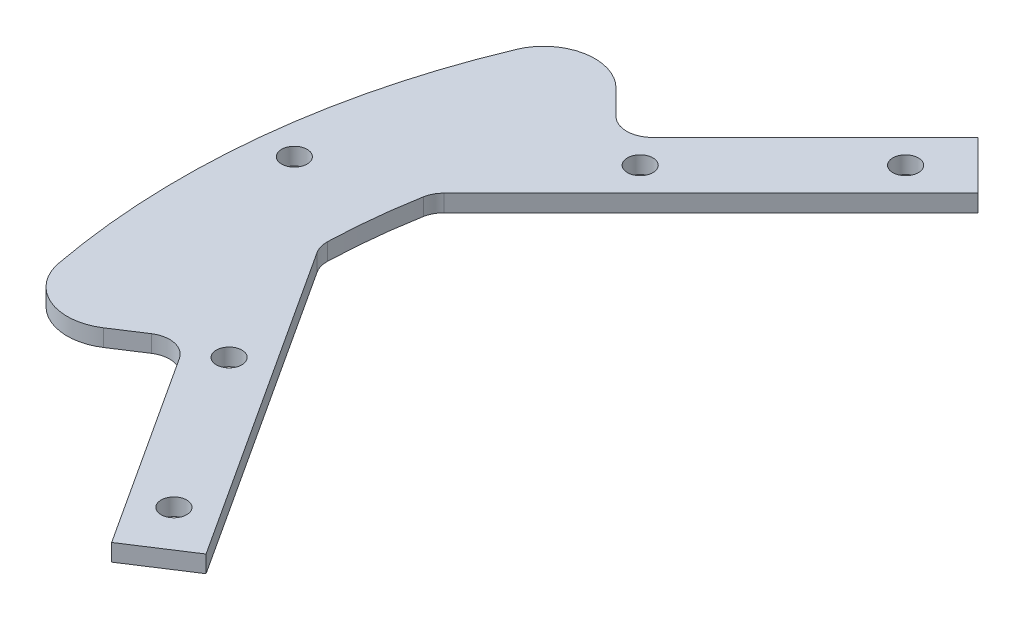
from build123d import *

# Parameters (mm, degrees)
SKETCH1_R                = 1.5
BOSS_EXTRUDE1_DEPTH      = 2
FILLET1_R                = 6
FILLET2_R                = 3
F_3_0_3_DIAMETER_HOLE1_D = 3


with BuildPart() as part:
    # Sketch1 → Boss-Extrude1 (new body)
    with BuildSketch(Plane(origin=(0, 0, 0), x_dir=(1, 0, 0), z_dir=(0, 1, 0))):
        with BuildLine():
            Line((-74.629040009, 40.687914512), (-63.639610307, 29.69848481))
            Line((-63.639610307, 29.69848481), (-42.426406871, 50.911688245))
            Line((-42.426406871, 50.911688245), (-36.769552622, 45.254833996))
            Line((-36.769552622, 45.254833996), (-68.72500623, 13.299380388))
            ThreePointArc((-68.72500623, 13.299380388), (-69.616532676, 7.316992429), (-69.988296617, 1.279975229))
            Line((-69.988296617, 1.279975229), (-45.375058731, -36.621087439))
            Line((-45.375058731, -36.621087439), (-52.084423274, -40.978199719))
            Line((-52.084423274, -40.978199719), (-68.423594325, -15.81808268))
            Line((-68.423594325, -15.81808268), (-81.457709532, -24.282536066))
            ThreePointArc((-81.457709532, -24.282536066), (-84.534361106, 8.884919378), (-74.629040009, 40.687914512))
        make_face()
        with Locations((-43.840620434, 43.840620434)):
            Circle(SKETCH1_R, mode=Mode.SUBTRACT)
        with Locations((-59.39696962, 28.284271247)):
            Circle(SKETCH1_R, mode=Mode.SUBTRACT)
        with Locations((-51.997575213, -33.767620171)):
            Circle(SKETCH1_R, mode=Mode.SUBTRACT)
        with Locations((-63.979633983, -15.316867676)):
            Circle(SKETCH1_R, mode=Mode.SUBTRACT)
    extrude(amount=BOSS_EXTRUDE1_DEPTH)

    # Fillet1
    fillet1_edges = [part.edges().sort_by_distance(p)[0] for p in [
        (-74.629040009, 1, -40.687914512),
        (-81.457709532, 1, 24.282536066),
    ]]
    fillet(fillet1_edges, radius=FILLET1_R)

    # Fillet2
    fillet2_edges = [part.edges().sort_by_distance(p)[0] for p in [
        (-63.639610307, 1, -29.69848481),
        (-68.72500623, 1, -13.299380388),
        (-69.988296617, 1, -1.279975229),
        (-68.423594325, 1, 15.81808268),
    ]]
    fillet(fillet2_edges, radius=FILLET2_R)

    # Ø3.0 (3) Diameter Hole1 (through all)
    with Locations(Plane(origin=(0, 2, 0), x_dir=(1, 0, 0), z_dir=(0, 1, 0))):
        with Locations((-80.534361106, 8.884919378)):
            Hole(F_3_0_3_DIAMETER_HOLE1_D / 2)


solid = part.part
